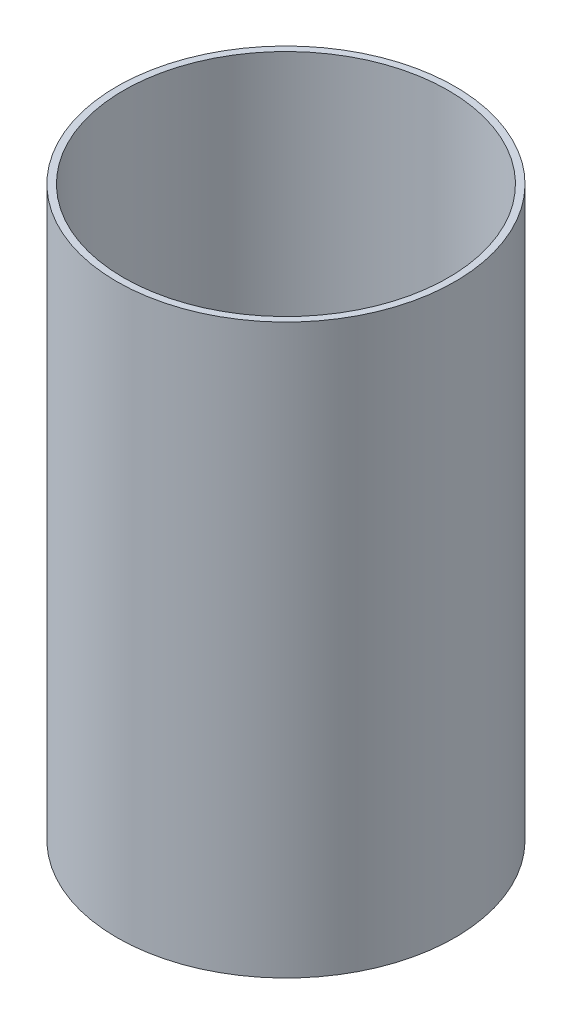
from build123d import *

# Parameters (mm, degrees)
SKETCH2_W = 1.5875
SKETCH2_H = 133.35


with BuildPart() as part:
    # Sketch2 → Revolve1 (revolve)
    with BuildSketch(Plane.XY):
        with Locations((-38.89375, -66.675)):
            Rectangle(SKETCH2_W, SKETCH2_H)
    revolve(axis=Axis((0, 55, 0), (0, -1, 0)))


solid = part.part
